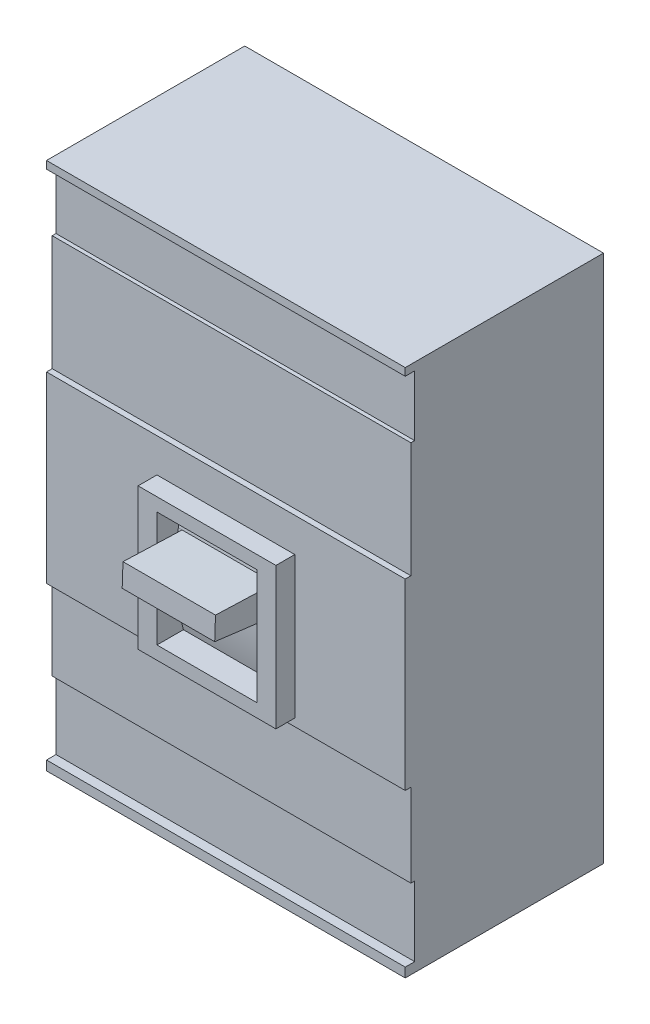
from build123d import *

# Parameters (mm, degrees)
CROQUIS1_W              = 190
CROQUIS1_H              = 280
SALIENTE_EXTRUIR1_DEPTH = 105
CROQUIS2_W              = 73
CROQUIS2_H              = 75
CROQUIS2_W_2            = 53
CROQUIS2_H_2            = 61
SALIENTE_EXTRUIR2_DEPTH = 10
CROQUIS3_W              = 190
CROQUIS3_H              = 32
CORTAR_EXTRUIR1_DEPTH   = 5
CROQUIS4_W              = 190
CROQUIS4_H              = 61
CORTAR_EXTRUIR2_DEPTH   = 3
CORTAR_EXTRUIR3_DEPTH   = 53
SALIENTE_EXTRUIR3_DEPTH = 53
CORTAR_EXTRUIR4_DEPTH   = 2
CORTAR_EXTRUIR5_DEPTH   = 2
CROQUIS10_W             = 190
CROQUIS10_H             = 44
CORTAR_EXTRUIR6_DEPTH   = 3
CROQUIS11_W             = 190
CROQUIS11_H             = 37
CORTAR_EXTRUIR7_DEPTH   = 5


with BuildPart() as part:
    # Croquis1 → Saliente-Extruir1 (new body)
    with BuildSketch(Plane.XY):
        Rectangle(CROQUIS1_W, CROQUIS1_H)
    extrude(amount=SALIENTE_EXTRUIR1_DEPTH)

    # Croquis2 → Saliente-Extruir2 (add)
    with BuildSketch(Plane.XY.offset(105)):
        with Locations((0, -12.5)):
            Rectangle(CROQUIS2_W, CROQUIS2_H)
        with Locations((0, -12.5)):
            Rectangle(CROQUIS2_W_2, CROQUIS2_H_2, mode=Mode.SUBTRACT)
    extrude(amount=SALIENTE_EXTRUIR2_DEPTH)

    # Croquis3 → Cortar-Extruir1 (cut)
    with BuildSketch(Plane.XY.offset(105)):
        with Locations((0, 120)):
            Rectangle(CROQUIS3_W, CROQUIS3_H)
    extrude(amount=-CORTAR_EXTRUIR1_DEPTH, mode=Mode.SUBTRACT)

    # Croquis4 → Cortar-Extruir2 (cut)
    with BuildSketch(Plane.XY.offset(105)):
        with Locations((0, 73.5)):
            Rectangle(CROQUIS4_W, CROQUIS4_H)
    extrude(amount=-CORTAR_EXTRUIR2_DEPTH, mode=Mode.SUBTRACT)

    # Croquis6 → Cortar-Extruir3 (cut)
    with BuildSketch(Plane(origin=(-26.5, 0, 0), x_dir=(0, 0, -1), z_dir=(1, 0, 0))):
        with BuildLine():
            Line((-105, 18), (-101, 18))
            ThreePointArc((-101, 18), (-105, -12.5), (-101, -43))
            Line((-101, -43), (-105, -43))
            Line((-105, -43), (-107.940115758, -14.951898157))
            Line((-107.940115758, -14.951898157), (-105, 18))
        make_face()
    extrude(amount=CORTAR_EXTRUIR3_DEPTH, mode=Mode.SUBTRACT)

    # Croquis7 → Saliente-Extruir3 (add)
    with BuildSketch(Plane(origin=(-26.5, 0, 0), x_dir=(0, 0, -1), z_dir=(1, 0, 0))):
        with BuildLine():
            Line((-103.681451712, 5.111942251), (-135, 6.21315585))
            Line((-135, 6.21315585), (-135.421940476, -5.78684415))
            Line((-135.421940476, -5.78684415), (-104.965398794, -9.639204549))
            ThreePointArc((-104.965398794, -9.639204549), (-104.554477707, -2.24352023), (-103.681451712, 5.111942251))
        make_face()
    extrude(amount=SALIENTE_EXTRUIR3_DEPTH)

    # Croquis8 → Cortar-Extruir4 (cut)
    with BuildSketch(Plane(origin=(26.5, 0, 0), x_dir=(0, 0, -1), z_dir=(1, 0, 0))):
        with BuildLine():
            Line((-135, 6.21315585), (-103.681451712, 5.111942251))
            ThreePointArc((-103.681451712, 5.111942251), (-104.652420764, -2.234995218), (-104.965398794, -9.639204549))
            Line((-104.965398794, -9.639204549), (-135.421940476, -5.78684415))
            Line((-135.421940476, -5.78684415), (-135, 6.21315585))
        make_face()
    extrude(amount=-CORTAR_EXTRUIR4_DEPTH, mode=Mode.SUBTRACT)

    # Croquis9 → Cortar-Extruir5 (cut)
    with BuildSketch(Plane.ZY.offset(26.5)):
        with BuildLine():
            Line((103.681451712, 5.111942251), (135, 6.21315585))
            Line((135, 6.21315585), (135.421940476, -5.78684415))
            Line((135.421940476, -5.78684415), (104.965398794, -9.639204549))
            ThreePointArc((104.965398794, -9.639204549), (104.652420764, -2.234995218), (103.681451712, 5.111942251))
        make_face()
    extrude(amount=-CORTAR_EXTRUIR5_DEPTH, mode=Mode.SUBTRACT)

    # Croquis10 → Cortar-Extruir6 (cut)
    with BuildSketch(Plane.XY.offset(105)):
        with Locations((0, -76)):
            Rectangle(CROQUIS10_W, CROQUIS10_H)
    extrude(amount=-CORTAR_EXTRUIR6_DEPTH, mode=Mode.SUBTRACT)

    # Croquis11 → Cortar-Extruir7 (cut)
    with BuildSketch(Plane.XY.offset(105)):
        with Locations((0, -116.5)):
            Rectangle(CROQUIS11_W, CROQUIS11_H)
    extrude(amount=-CORTAR_EXTRUIR7_DEPTH, mode=Mode.SUBTRACT)


solid = part.part
